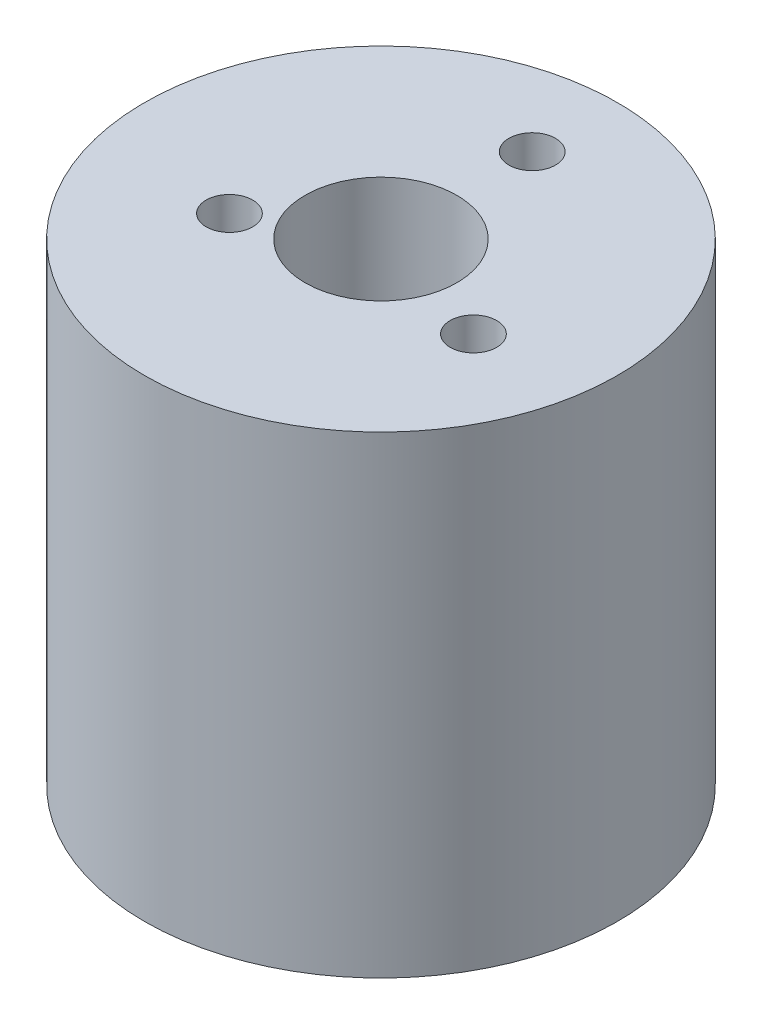
from build123d import *

# Parameters (mm, degrees)
SKETCH1_R           = 12.7
BOSS_EXTRUDE1_DEPTH = 25.4
SKETCH2_R           = 4.075
CUT_EXTRUDE1_DEPTH  = 19.05
SKETCH3_R           = 1.25
CUT_EXTRUDE2_DEPTH  = 12


with BuildPart() as part:
    # Sketch1 → Boss-Extrude1 (new body)
    with BuildSketch(Plane(origin=(0, 0, 0), x_dir=(1, 0, 0), z_dir=(0, 1, 0))):
        Circle(SKETCH1_R)
    extrude(amount=BOSS_EXTRUDE1_DEPTH)

    # Sketch2 → Cut-Extrude1 (cut)
    with BuildSketch(Plane(origin=(0, 25.4, 0), x_dir=(1, 0, 0), z_dir=(0, 1, 0))):
        Circle(SKETCH2_R)
    extrude(amount=-CUT_EXTRUDE1_DEPTH, mode=Mode.SUBTRACT)

    # Sketch3 → Cut-Extrude2 (cut)
    with BuildSketch(Plane(origin=(0, 25.4, 0), x_dir=(1, 0, 0), z_dir=(0, 1, 0))):
        with Locations((6.899904191, -1.930944627)):
            Circle(SKETCH3_R)
        with Locations((-5.25875141, -2.878464627)):
            Circle(SKETCH3_R)
        with Locations((0, 8.125)):
            Circle(SKETCH3_R)
    extrude(amount=-CUT_EXTRUDE2_DEPTH, mode=Mode.SUBTRACT)


solid = part.part
